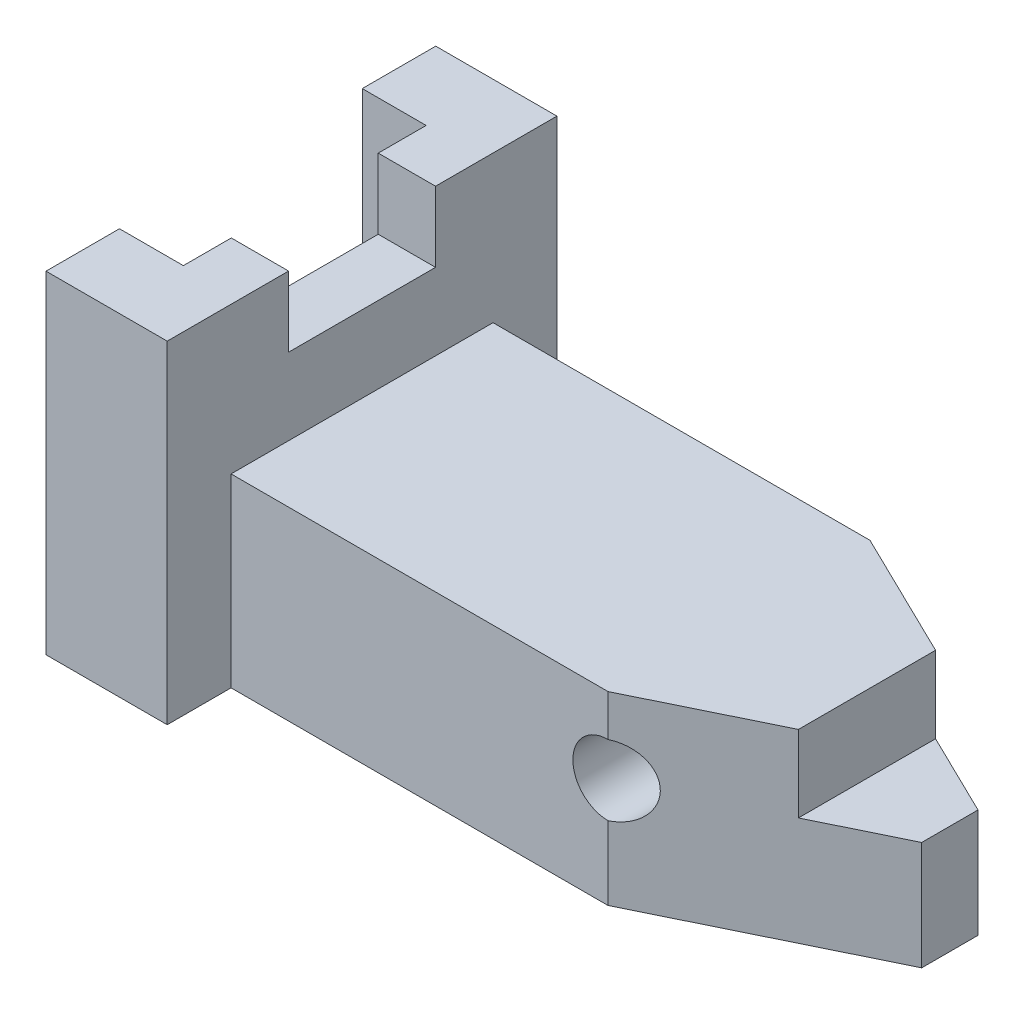
from build123d import *

# Parameters (mm, degrees)
BOSS_EXTRUDE1_DEPTH = 52
SKETCH2_W           = 41
SKETCH2_H           = 23
CUT_EXTRUDE1_DEPTH  = 92
SKETCH3_W           = 10
SKETCH3_H           = 52
CUT_EXTRUDE2_DEPTH  = 9.031229
CUT_EXTRUDE3_DEPTH  = 35
SKETCH5_W           = 20
SKETCH5_H           = 38
CUT_EXTRUDE4_DEPTH  = 62
SKETCH6_W           = 9.816407164
SKETCH6_H           = 23
CUT_EXTRUDE5_DEPTH  = 11
SKETCH8_R           = 5.5
CUT_EXTRUDE6_DEPTH  = 52


with BuildPart() as part:
    # Sketch1 → Boss-Extrude1 (new body)
    with BuildSketch(Plane(origin=(0, 0, 0), x_dir=(1, 0, 0), z_dir=(0, 1, 0))):
        Polygon((0, 30.5), (0, -30.5), (28, -30.5), (28, -20.5), (77.968771248, -20.5), (110.968771248, -4.404824577), (110.968771248, 4.404824577), (77.968771248, 20.5), (28, 20.5), (28, 30.5), align=None)
    extrude(amount=BOSS_EXTRUDE1_DEPTH)

    # Sketch2 → Cut-Extrude1 (cut)
    with BuildSketch(Plane(origin=(110.968771248, 0, 0), x_dir=(0, 0, -1), z_dir=(1, 0, 0))):
        with Locations((0, 40.5)):
            Rectangle(SKETCH2_W, SKETCH2_H)
    extrude(amount=-CUT_EXTRUDE1_DEPTH, mode=Mode.SUBTRACT)

    # Sketch3 → Cut-Extrude2 (cut)
    with BuildSketch(Plane(origin=(28, 0, 0), x_dir=(0, 0, -1), z_dir=(1, 0, 0))):
        with Locations((-25.5, 26)):
            Rectangle(SKETCH3_W, SKETCH3_H)
        with Locations((25.5, 26)):
            Rectangle(SKETCH3_W, SKETCH3_H)
    extrude(amount=-CUT_EXTRUDE2_DEPTH, mode=Mode.SUBTRACT)

    # Sketch4 → Cut-Extrude3 (cut)
    with BuildSketch(Plane(origin=(0, 52, 0), x_dir=(1, 0, 0), z_dir=(0, 1, 0))):
        Polygon((120, 0), (120, 12.404317322), (98, 12.404317322), (98, -13.293630883), (120, -13.293630883), align=None)
    extrude(amount=-CUT_EXTRUDE3_DEPTH, mode=Mode.SUBTRACT)

    # Sketch5 → Cut-Extrude4 (cut)
    with BuildSketch(Plane(origin=(0, 52, 0), x_dir=(1, 0, 0), z_dir=(0, 1, 0))):
        Rectangle(SKETCH5_W, SKETCH5_H)
    extrude(amount=-CUT_EXTRUDE4_DEPTH, mode=Mode.SUBTRACT)

    # Sketch6 → Cut-Extrude5 (cut)
    with BuildSketch(Plane(origin=(0, 52, 0), x_dir=(1, 0, 0), z_dir=(0, 1, 0))):
        with Locations((14.060567666, 0)):
            Rectangle(SKETCH6_W, SKETCH6_H)
    extrude(amount=-CUT_EXTRUDE5_DEPTH, mode=Mode.SUBTRACT)

    # Sketch8 → Cut-Extrude6 (cut, through all)
    with BuildSketch(Plane.XY.offset(20.5)):
        with Locations((77.968771248, 17)):
            Circle(SKETCH8_R)
    extrude(amount=-CUT_EXTRUDE6_DEPTH, mode=Mode.SUBTRACT)


solid = part.part
